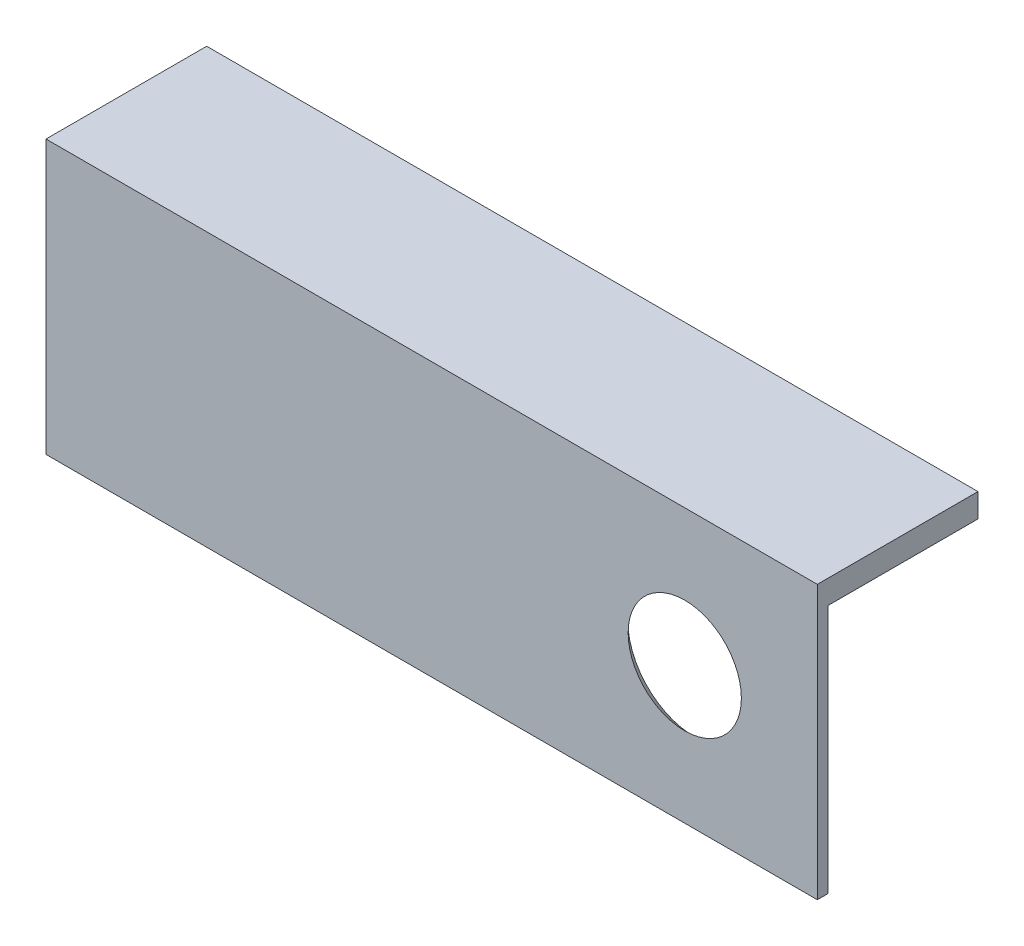
from build123d import *

# Parameters (mm, degrees)
CROQUIS1_W              = 48
CROQUIS1_H              = 17
SALIENTE_EXTRUIR1_DEPTH = 10
CROQUIS7_W              = 9.346110156
CROQUIS7_H              = 15.524186193
CORTAR_EXTRUIR1_DEPTH   = 49


with BuildPart() as part:
    # Croquis1 → Saliente-Extruir1 (new body)
    with BuildSketch(Plane.XY):
        Rectangle(CROQUIS1_W, CROQUIS1_H)
    extrude(amount=SALIENTE_EXTRUIR1_DEPTH)

    # Croquis7 → Cortar-Extruir1 (cut, through all)
    with BuildSketch(Plane.ZY.offset(24)):
        with Locations((4.673055078, -0.737906903)):
            Rectangle(CROQUIS7_W, CROQUIS7_H)
    extrude(amount=-CORTAR_EXTRUIR1_DEPTH, mode=Mode.SUBTRACT)

    # Croquis12 → Taladro de margen para M3.53 (revolve, cut)
    with BuildSketch(Plane(origin=(15.750802653, 0, 9.346110156), x_dir=(0, 1, 0), z_dir=(1, 0, 0))):
        Polygon((0, 0), (0, 0.653889844), (1.95, 0.653889844), (1.95, 2.172799743), (4.2, 0), align=None)
    revolve(axis=Axis((15.750802653, 0, 2.996110156), (0, 0, 1)), mode=Mode.SUBTRACT)


solid = part.part
